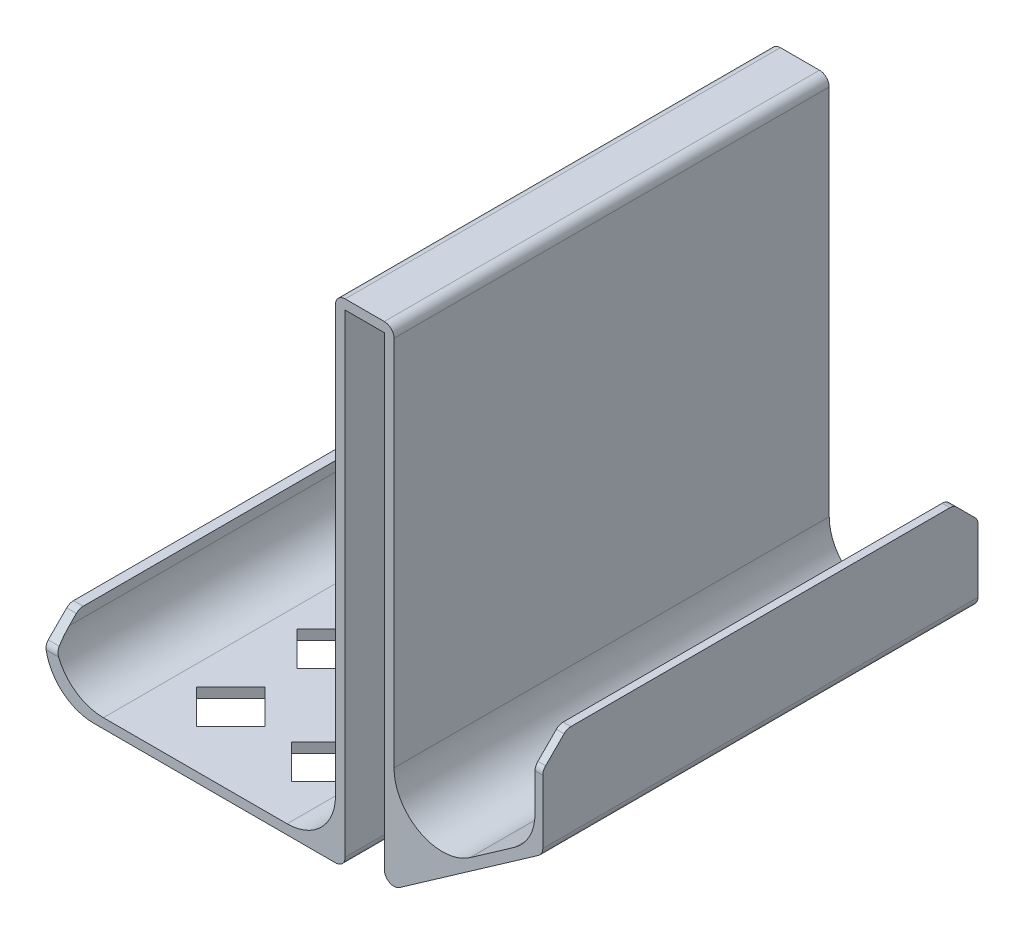
from build123d import *

# Parameters (mm, degrees)
BOSS_EXTRU_1_DEPTH              = 90
CONG_1_R                        = 10
CHANFREIN1_SIZE                 = 5
CONG_2_R                        = 2
ENL_V_MAT_EXTRU_1_DEPTH         = 2
R_P_TITION_LIN_AIRE1_COUNT      = 4
R_P_TITION_LIN_AIRE1_PITCH      = 20.828705533
R_P_TITION_LIN_AIRE1_COUNT_DIR2 = 2
R_P_TITION_LIN_AIRE1_PITCH_DIR2 = 19.691351592


with BuildPart() as part:
    # Esquisse1 → Boss.-Extru.1 (new body)
    with BuildSketch(Plane.XY):
        Polygon((-4.05, 2.83584053), (-4.05, 102.83584053), (4.05, 102.83584053), (4.05, 2.83584053), (36.816081772, 25.778897984), (36.816081772, 45.778897984), (35.216081772, 45.778897984), (35.216081772, 27.1001151), (6.05, 6.677804784), (6.05, 104.83584053), (-6.05, 104.83584053), (-6.05, 4.83584053), (-64.05, 4.83584053), (-64.05, 16.888959942), (-66.05, 16.888959942), (-66.05, 2.83584053), (-6.05, 2.83584053), align=None)
    extrude(amount=BOSS_EXTRU_1_DEPTH)

    # Congé1
    cong_1_edges = [part.edges().sort_by_distance(p)[0] for p in [
        (-66.05, 2.83584053, 45),
        (-64.05, 4.83584053, 45),
        (-6.05, 4.83584053, 45),
        (6.05, 6.677804784, 45),
        (35.216081772, 27.1001151, 45),
    ]]
    fillet(cong_1_edges, radius=CONG_1_R)

    # Chanfrein1
    chanfrein1_edges = [part.edges().sort_by_distance(p)[0] for p in [
        (36.016081772, 45.778897984, 0),
        (36.016081772, 45.778897984, 90),
        (-65.05, 16.888959942, 0),
        (-65.05, 16.888959942, 90),
    ]]
    chamfer(chanfrein1_edges, length=CHANFREIN1_SIZE)

    # Congé2
    cong_2_edges = [part.edges().sort_by_distance(p)[0] for p in [
        (36.816081772, 25.778897984, 45),
        (4.05, 2.83584053, 45),
        (36.016081772, 40.778897984, 90),
        (36.016081772, 40.778897984, 0),
        (36.016081772, 45.778897984, 5),
        (36.016081772, 45.778897984, 85),
        (-64.805502489, 11.888959942, 90),
        (-65.05, 16.888959942, 85),
        (-64.805502489, 11.888959942, 0),
        (-65.05, 16.888959942, 5),
        (6.05, 104.83584053, 45),
        (-6.05, 104.83584053, 45),
        (-4.05, 2.83584053, 45),
    ]]
    fillet(cong_2_edges, radius=CONG_2_R)

    # Esquisse2 → Enlèv. mat.-Extru.1 (cut)
    with BuildSketch(Plane.XZ.offset(-2.83584053)):
        Polygon((-49.883487215, 12.442815588), (-42.812419404, 19.5138834), (-35.741351592, 12.442815588), (-42.812419404, 5.371747776), align=None)
    enl_v_mat_extru_1 = extrude(amount=-ENL_V_MAT_EXTRU_1_DEPTH, mode=Mode.SUBTRACT)

    # Répétition linéaire1: Enl_v. mat.-Extru.1 4 × 2
    with Locations(*[(j * R_P_TITION_LIN_AIRE1_PITCH_DIR2, 0, i * R_P_TITION_LIN_AIRE1_PITCH) for i in range(R_P_TITION_LIN_AIRE1_COUNT) for j in range(R_P_TITION_LIN_AIRE1_COUNT_DIR2) if (i, j) != (0, 0)]):
        add(enl_v_mat_extru_1, mode=Mode.SUBTRACT)


solid = part.part
